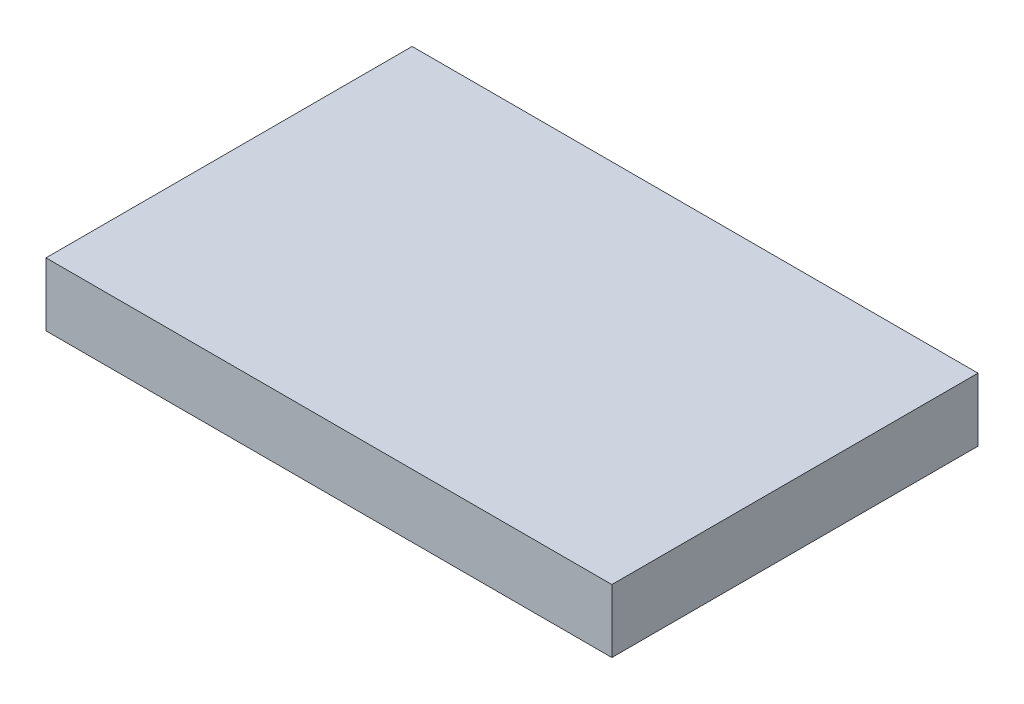
from build123d import *

# Parameters (mm, degrees)
SKETCH1_W           = 86.36
SKETCH1_H           = 55.88
BOSS_EXTRUDE1_DEPTH = 9.652


with BuildPart() as part:
    # Sketch1 → Boss-Extrude1 (new body)
    with BuildSketch(Plane(origin=(0, 0, 0), x_dir=(1, 0, 0), z_dir=(0, 1, 0))):
        with Locations((43.18, 27.94)):
            Rectangle(SKETCH1_W, SKETCH1_H)
    extrude(amount=BOSS_EXTRUDE1_DEPTH)


solid = part.part
